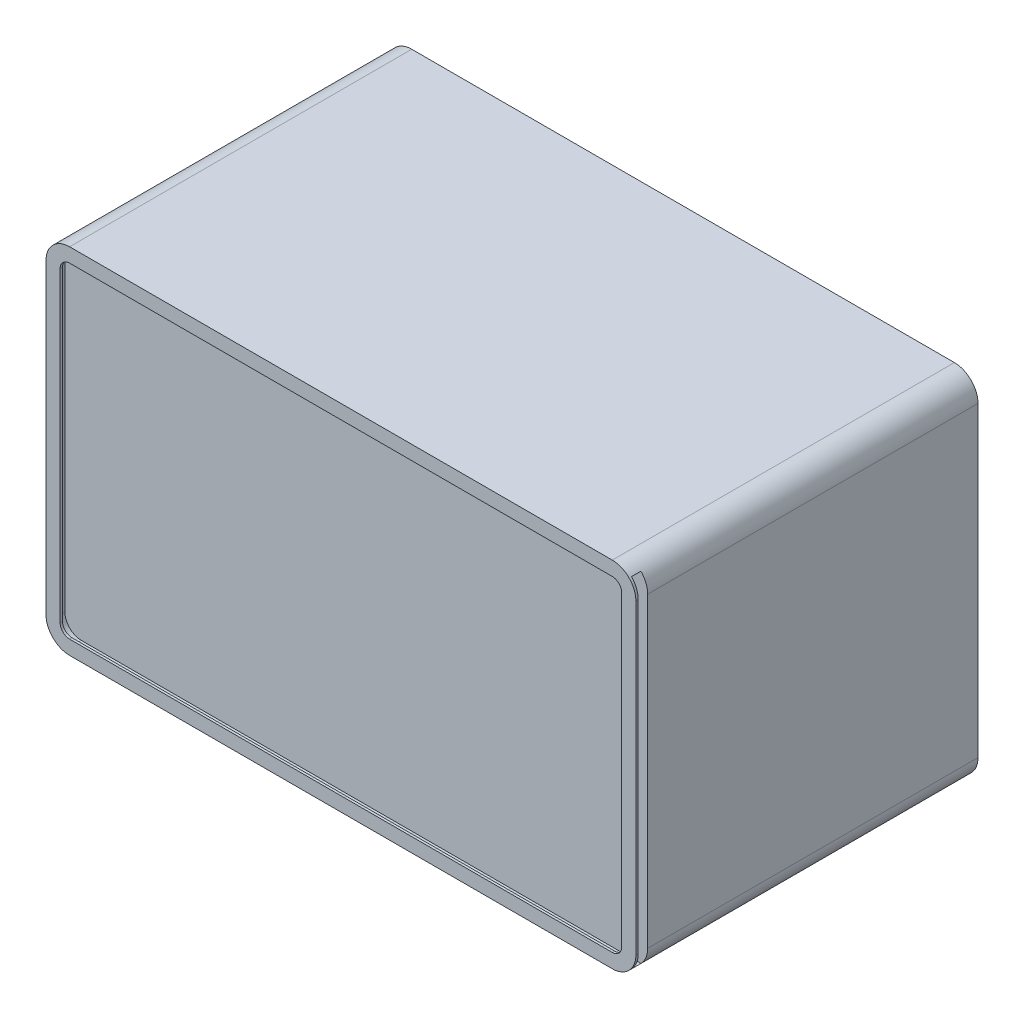
from build123d import *

# Parameters (mm, degrees)
BOSS_EXTRUDE1_DEPTH = 150
SHELL2_T            = -3
BOSS_EXTRUDE2_DEPTH = 3
CUT_EXTRUDE1_DEPTH  = 5
BOSS_EXTRUDE3_DEPTH = 5
BOSS_EXTRUDE4_DEPTH = 1
SKETCH10_W          = 5
SKETCH10_H          = 144
CUT_EXTRUDE2_DEPTH  = 8
SKETCH11_W          = 5
SKETCH11_H          = 144
CUT_EXTRUDE3_DEPTH  = 8
SKETCH12_W          = 1
SKETCH12_H          = 144
BOSS_EXTRUDE5_DEPTH = 16
CUT_EXTRUDE4_DEPTH  = 8
CUT_EXTRUDE5_DEPTH  = 8
SKETCH15_R          = 4
CUT_EXTRUDE13_DEPTH = 9


with BuildPart() as part:
    # Sketch2 → Boss-Extrude1 (new body)
    with BuildSketch(Plane.XY):
        with BuildLine():
            Line((10, 0), (240, 0))
            ThreePointArc((240, 0), (247.071067812, 2.928932188), (250, 10))
            Line((250, 10), (250, 140))
            ThreePointArc((250, 140), (247.071067812, 147.071067812), (240, 150))
            Line((240, 150), (10, 150))
            ThreePointArc((10, 150), (2.928932188, 147.071067812), (0, 140))
            Line((0, 140), (0, 10))
            ThreePointArc((0, 10), (2.928932188, 2.928932188), (10, 0))
        make_face()
    extrude(amount=BOSS_EXTRUDE1_DEPTH)

    # Shell2
    shell2_openings = [part.faces().sort_by_distance(p)[0] for p in [
        (125, 75, 0),
    ]]
    offset(amount=SHELL2_T, openings=shell2_openings, kind=Kind.INTERSECTION)

    # Sketch4 → Boss-Extrude2 (add)
    with BuildSketch(Plane(origin=(0, 0, 0), x_dir=(-1, 0, 0), z_dir=(0, 0, -1))):
        with BuildLine():
            Line((-10, 3), (-240, 3))
            ThreePointArc((-240, 3), (-244.949747468, 5.050252532), (-247, 10))
            Line((-247, 10), (-247, 140))
            ThreePointArc((-247, 140), (-244.949747468, 144.949747468), (-240, 147))
            Line((-240, 147), (-10, 147))
            ThreePointArc((-10, 147), (-5.050252532, 144.949747468), (-3, 140))
            Line((-3, 140), (-3, 10))
            ThreePointArc((-3, 10), (-5.050252532, 5.050252532), (-10, 3))
        make_face()
    extrude(amount=-BOSS_EXTRUDE2_DEPTH)

    # Sketch5 → Cut-Extrude1 (cut)
    with BuildSketch(Plane.XY.offset(150)):
        with BuildLine():
            Line((240, 150), (10, 150))
            ThreePointArc((10, 150), (2.928932188, 147.071067812), (0, 140))
            Line((0, 140), (0, 10))
            ThreePointArc((0, 10), (2.928932188, 2.928932188), (10, 0))
            Line((10, 0), (240, 0))
            ThreePointArc((240, 0), (247.071067812, 2.928932188), (250, 10))
            Line((250, 10), (250, 140))
            ThreePointArc((250, 140), (247.071067812, 147.071067812), (240, 150))
        make_face()
    extrude(amount=-CUT_EXTRUDE1_DEPTH, mode=Mode.SUBTRACT)

    # Sketch6 → Boss-Extrude3 (add)
    with BuildSketch(Plane.XY.offset(135)):
        with BuildLine():
            Line((10, 3), (240, 3))
            ThreePointArc((240, 3), (244.949747468, 5.050252532), (247, 10))
            Line((247, 10), (247, 140))
            ThreePointArc((247, 140), (244.949747468, 144.949747468), (240, 147))
            Line((240, 147), (10, 147))
            ThreePointArc((10, 147), (5.050252532, 144.949747468), (3, 140))
            Line((3, 140), (3, 10))
            ThreePointArc((3, 10), (5.050252532, 5.050252532), (10, 3))
        make_face()
    extrude(amount=BOSS_EXTRUDE3_DEPTH)

    # Sketch7 → Boss-Extrude4 (add)
    with BuildSketch(Plane.XY.offset(144)):
        with BuildLine():
            Line((10, 3), (240, 3))
            ThreePointArc((240, 3), (244.949747468, 5.050252532), (247, 10))
            Line((247, 10), (247, 140))
            ThreePointArc((247, 140), (244.949747468, 144.949747468), (240, 147))
            Line((240, 147), (10, 147))
            ThreePointArc((10, 147), (5.050252532, 144.949747468), (3, 140))
            Line((3, 140), (3, 10))
            ThreePointArc((3, 10), (5.050252532, 5.050252532), (10, 3))
        make_face()
        with BuildLine():
            Line((6, 140), (6, 10))
            ThreePointArc((6, 10), (7.171572875, 7.171572875), (10, 6))
            Line((10, 6), (240, 6))
            ThreePointArc((240, 6), (242.828427125, 7.171572875), (244, 10))
            Line((244, 10), (244, 140))
            ThreePointArc((244, 140), (242.828427125, 142.828427125), (240, 144))
            Line((240, 144), (10, 144))
            ThreePointArc((10, 144), (7.171572875, 142.828427125), (6, 140))
        make_face(mode=Mode.SUBTRACT)
    extrude(amount=BOSS_EXTRUDE4_DEPTH)

    # Sketch10 → Cut-Extrude2 (cut)
    with BuildSketch(Plane(origin=(250, 0, 0), x_dir=(0, 0, -1), z_dir=(1, 0, 0))):
        with Locations((-141.5, 75)):
            Rectangle(SKETCH10_W, SKETCH10_H)
    extrude(amount=-CUT_EXTRUDE2_DEPTH, mode=Mode.SUBTRACT)

    # Sketch11 → Cut-Extrude3 (cut)
    with BuildSketch(Plane(origin=(242, 0, 0), x_dir=(0, 0, -1), z_dir=(1, 0, 0))):
        with Locations((-141.5, 75)):
            Rectangle(SKETCH11_W, SKETCH11_H)
    extrude(amount=-CUT_EXTRUDE3_DEPTH, mode=Mode.SUBTRACT)

    # Sketch12 → Boss-Extrude5 (add)
    with BuildSketch(Plane(origin=(234, 0, 0), x_dir=(0, 0, -1), z_dir=(1, 0, 0))):
        with Locations((-139.5, 75)):
            Rectangle(SKETCH12_W, SKETCH12_H)
    extrude(amount=BOSS_EXTRUDE5_DEPTH)

    # Sketch13 → Cut-Extrude4 (cut)
    with BuildSketch(Plane(origin=(0, 0, 139), x_dir=(-1, 0, 0), z_dir=(0, 0, -1))):
        with BuildLine():
            Line((-250, 3), (-247.141428429, 3))
            ThreePointArc((-247.141428429, 3), (-249.257815193, 6.219410382), (-250, 10))
            Line((-250, 10), (-250, 3))
        make_face()
    extrude(amount=-CUT_EXTRUDE4_DEPTH, mode=Mode.SUBTRACT)

    # Sketch14 → Cut-Extrude5 (cut)
    with BuildSketch(Plane(origin=(0, 0, 139), x_dir=(-1, 0, 0), z_dir=(0, 0, -1))):
        with BuildLine():
            Line((-250, 147), (-250, 140))
            ThreePointArc((-250, 140), (-249.257815193, 143.780589618), (-247.141428429, 147))
            Line((-247.141428429, 147), (-250, 147))
        make_face()
    extrude(amount=-CUT_EXTRUDE5_DEPTH, mode=Mode.SUBTRACT)

    # Sketch15 → Cut-Extrude13 (cut)
    with BuildSketch(Plane.XZ):
        with Locations((102.5, 97.5)):
            Circle(SKETCH15_R)
        with Locations((102.5, 47.5)):
            Circle(SKETCH15_R)
        with Locations((147.5, 47.5)):
            Circle(SKETCH15_R)
        with Locations((147.5, 97.5)):
            Circle(SKETCH15_R)
    extrude(amount=-CUT_EXTRUDE13_DEPTH, mode=Mode.SUBTRACT)


solid = part.part
